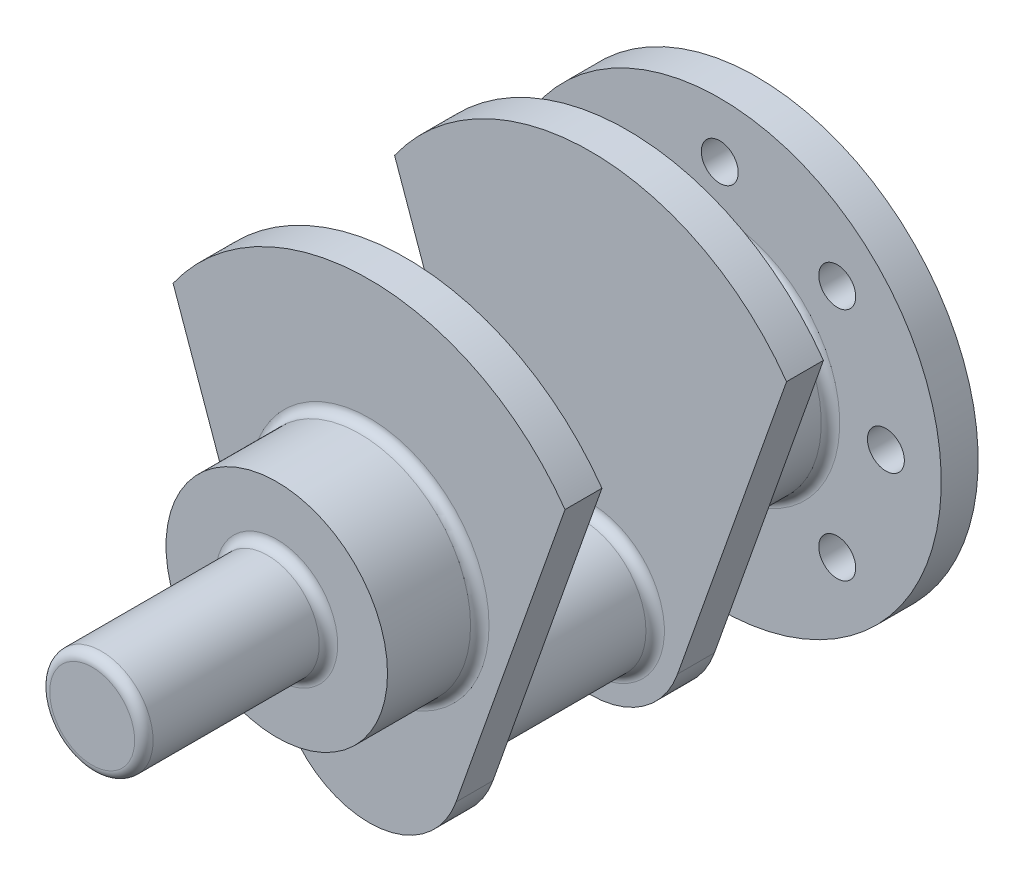
from build123d import *

# Parameters (mm, degrees)
SKETCH_1_R      = 50
EXTRUDE_1_DEPTH = 20
SKETCH_2_R      = 35
EXTRUDE_2_DEPTH = 100
SKETCH_3_R      = 60
EXTRUDE_3_DEPTH = 50
SKETCH_5_R      = 28
EXTRUDE_4_DEPTH = 100
SKETCH_7_R      = 120
SKETCH_7_R_2    = 10
EXTRUDE_5_DEPTH = 20
FILLET_1_R      = 5


with BuildPart() as part:
    # 草图1 → 凸台-拉伸1 (new body)
    with BuildSketch(Plane.XY):
        with BuildLine():
            ThreePointArc((106.16809457, 75.022234674), (0, 130), (-106.16809457, 75.022234674))
            Line((-106.16809457, 75.022234674), (-47.132074555, -91.690342962))
            ThreePointArc((-47.132074555, -91.690342962), (-8.467475192, -25.722197047), (50, -75))
            ThreePointArc((50, -75), (49.277802953, -83.467475192), (47.132074555, -91.690342962))
            Line((47.132074555, -91.690342962), (106.16809457, 75.022234674))
        make_face()
        with Locations((0, -75)):
            Circle(SKETCH_1_R)
    extrude_1 = extrude(amount=EXTRUDE_1_DEPTH)

    # 草图2 → 凸台-拉伸2 (add)
    with BuildSketch(Plane(origin=(0, 0, 0), x_dir=(-1, 0, 0), z_dir=(0, 0, -1))):
        with Locations((0, -75)):
            Circle(SKETCH_2_R)
    extrude(amount=EXTRUDE_2_DEPTH)

    # 草图3 → 凸台-拉伸3 (add)
    with BuildSketch(Plane.XY.offset(20)):
        Circle(SKETCH_3_R)
    extrude_3 = extrude(amount=EXTRUDE_3_DEPTH)

    # 镜向1: 凸台-拉伸1, 凸台-拉伸3 across plane
    add(extrude_1.mirror(Plane(origin=(0, 0, -50), x_dir=(1, 0, 0), z_dir=(0, 0, -1))))
    add(extrude_3.mirror(Plane(origin=(0, 0, -50), x_dir=(1, 0, 0), z_dir=(0, 0, -1))))

    # 草图5 → 凸台-拉伸4 (add)
    with BuildSketch(Plane.XY.offset(70)):
        Circle(SKETCH_5_R)
    extrude(amount=EXTRUDE_4_DEPTH)

    # 草图7 → 凸台-拉伸5 (add)
    with BuildSketch(Plane(origin=(0, 0, -170), x_dir=(-1, 0, 0), z_dir=(0, 0, -1))):
        Circle(SKETCH_7_R)
        with Locations((0, 90)):
            Circle(SKETCH_7_R_2, mode=Mode.SUBTRACT)
        with Locations((63.639610307, 63.639610307)):
            Circle(SKETCH_7_R_2, mode=Mode.SUBTRACT)
        with Locations((90, 0)):
            Circle(SKETCH_7_R_2, mode=Mode.SUBTRACT)
        with Locations((63.639610307, -63.639610307)):
            Circle(SKETCH_7_R_2, mode=Mode.SUBTRACT)
        with Locations((0, -90)):
            Circle(SKETCH_7_R_2, mode=Mode.SUBTRACT)
        with Locations((-63.639610307, -63.639610307)):
            Circle(SKETCH_7_R_2, mode=Mode.SUBTRACT)
        with Locations((-90, 0)):
            Circle(SKETCH_7_R_2, mode=Mode.SUBTRACT)
        with Locations((-63.639610307, 63.639610307)):
            Circle(SKETCH_7_R_2, mode=Mode.SUBTRACT)
    extrude(amount=EXTRUDE_5_DEPTH)

    # 圆角1
    fillet_1_edges = [part.edges().sort_by_distance(p)[0] for p in [
        (35, -75, 0),
        (35, -75, -100),
        (-60, 0, 20),
        (-60, 0, -120),
        (-28, 0, 70),
        (-28, 0, 170),
        (-60, 0, -170),
    ]]
    fillet(fillet_1_edges, radius=FILLET_1_R)


solid = part.part
